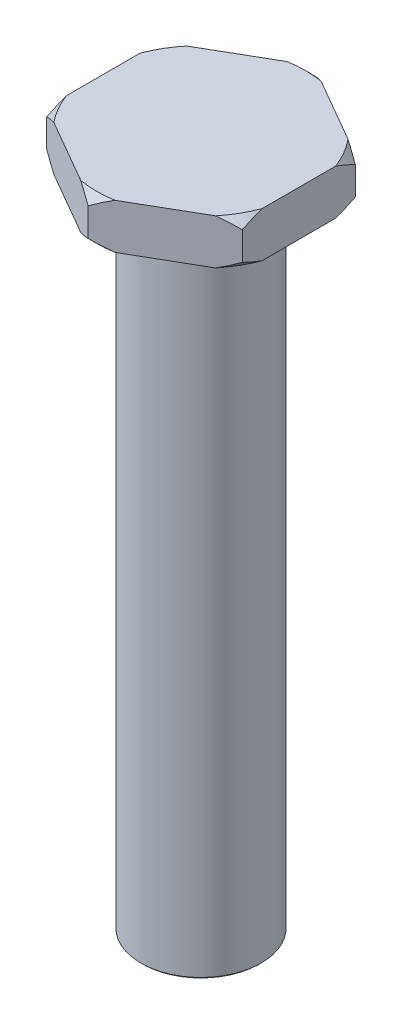
from build123d import *

# Parameters (mm, degrees)
EXTRUDE_1_DEPTH = 3
SKETCH_2_R      = 4
EXTRUDE_2_DEPTH = 43
CHAMFER_1_SIZE  = 0.1


with BuildPart() as part:
    # 草图1 → 凸台-拉伸1 (new body)
    with BuildSketch(Plane(origin=(0, 0, 0), x_dir=(1, 0, 0), z_dir=(0, 1, 0))):
        Polygon((0, 7.505553499), (-6.5, 3.75277675), (-6.5, -3.75277675), (0, -7.505553499), (6.5, -3.75277675), (6.5, 3.75277675), align=None)
    extrude(amount=EXTRUDE_1_DEPTH)

    # 草图2 → 凸台-拉伸2 (add)
    with BuildSketch(Plane.XZ):
        Circle(SKETCH_2_R)
    extrude(amount=EXTRUDE_2_DEPTH)

    # 倒角1
    chamfer_1_edges = [part.edges().sort_by_distance(p)[0] for p in [
        (-4, -43, 0),
    ]]
    chamfer(chamfer_1_edges, length=CHAMFER_1_SIZE)

    # 草图5 → 切除-旋转2 (revolve, cut)
    with BuildSketch(Plane(origin=(0, 0, 0), x_dir=(0, 0, -1), z_dir=(1, 0, 0))):
        Polygon((-6.945553499, 3), (-7.505553499, 2.44), (-7.505553499, 3), align=None)
        Polygon((-7.505553499, 0), (-7.505553499, 0.56), (-6.945553499, 0), align=None)
    revolve(axis=Axis((0, 3, 0), (0, 1, 0)), mode=Mode.SUBTRACT)


solid = part.part
